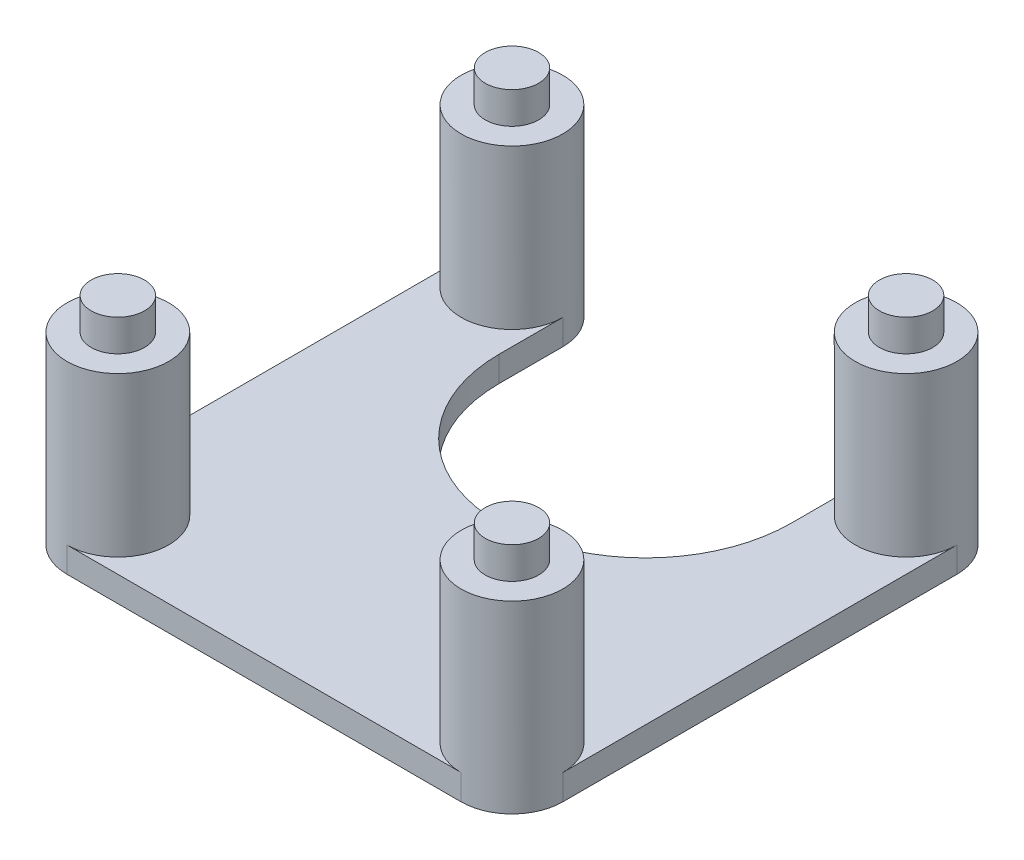
from build123d import *

# Parameters (mm, degrees)
SKETCH1_R             = 4
BOSS_EXTRUDE1_DEPTH   = 12.5
BOSS_EXTRUDE1_2_DEPTH = 12.5
BOSS_EXTRUDE1_3_DEPTH = 12.5
BOSS_EXTRUDE1_4_DEPTH = 12.5
SKETCH2_R             = 2.1
BOSS_EXTRUDE2_DEPTH   = 2.5
BOSS_EXTRUDE3_DEPTH   = 2


with BuildPart() as part:
    # Sketch1 → Boss-Extrude1 (new body)
    with BuildSketch(Plane(origin=(0, 0, 0), x_dir=(1, 0, 0), z_dir=(0, 1, 0))):
        with Locations((-15.5, -15.5)):
            Circle(SKETCH1_R)
    extrude(amount=BOSS_EXTRUDE1_DEPTH)



with BuildPart() as body_2:
    # Sketch1 → Boss-Extrude1 2 (new body)
    with BuildSketch(Plane(origin=(0, 0, 0), x_dir=(1, 0, 0), z_dir=(0, 1, 0))):
        with Locations((-15.5, 15.5)):
            Circle(SKETCH1_R)
    extrude(amount=BOSS_EXTRUDE1_2_DEPTH)


with BuildPart() as body_3:
    # Sketch1 → Boss-Extrude1 3 (new body)
    with BuildSketch(Plane(origin=(0, 0, 0), x_dir=(1, 0, 0), z_dir=(0, 1, 0))):
        with Locations((15.5, -15.5)):
            Circle(SKETCH1_R)
    extrude(amount=BOSS_EXTRUDE1_3_DEPTH)


with BuildPart() as body_4:
    # Sketch1 → Boss-Extrude1 4 (new body)
    with BuildSketch(Plane(origin=(0, 0, 0), x_dir=(1, 0, 0), z_dir=(0, 1, 0))):
        with Locations((15.5, 15.5)):
            Circle(SKETCH1_R)
    extrude(amount=BOSS_EXTRUDE1_4_DEPTH)


with BuildPart() as part_1:
    add(part.part)

    add(body_2.part)  # Boss-Extrude2 merges body 2

    add(body_3.part)  # Boss-Extrude2 merges body 3

    add(body_4.part)  # Boss-Extrude2 merges body 4
    # Sketch2 → Boss-Extrude2 (add)
    with BuildSketch(Plane(origin=(0, 12.5, 0), x_dir=(1, 0, 0), z_dir=(0, 1, 0))):
        with Locations((-15.5, 15.5)):
            Circle(SKETCH2_R)
        with Locations((15.5, 15.5)):
            Circle(SKETCH2_R)
        with Locations((15.5, -15.5)):
            Circle(SKETCH2_R)
        with Locations((-15.5, -15.5)):
            Circle(SKETCH2_R)
    extrude(amount=BOSS_EXTRUDE2_DEPTH)

    # Sketch3 → Boss-Extrude3 (add)
    with BuildSketch(Plane.XZ):
        with BuildLine():
            Line((-19.5, 15.5), (-19.5, -15.5))
            ThreePointArc((-19.5, -15.5), (-18.328427125, -18.328427125), (-15.5, -19.5))
            ThreePointArc((-15.5, -19.5), (-12.671572875, -18.328427125), (-11.5, -15.5))
            Line((-11.5, -15.5), (-11.5, -10.496545835))
            ThreePointArc((-11.5, -10.496545835), (0, 1.003454165), (11.5, -10.496545835))
            Line((11.5, -10.496545835), (11.5, -15.5))
            ThreePointArc((11.5, -15.5), (12.671572875, -18.328427125), (15.5, -19.5))
            ThreePointArc((15.5, -19.5), (18.328427125, -18.328427125), (19.5, -15.5))
            Line((19.5, -15.5), (19.5, 15.5))
            ThreePointArc((19.5, 15.5), (18.328427125, 18.328427125), (15.5, 19.5))
            Line((15.5, 19.5), (-15.5, 19.5))
            ThreePointArc((-15.5, 19.5), (-18.328427125, 18.328427125), (-19.5, 15.5))
        make_face()
    extrude(amount=BOSS_EXTRUDE3_DEPTH)


solid = part_1.part
